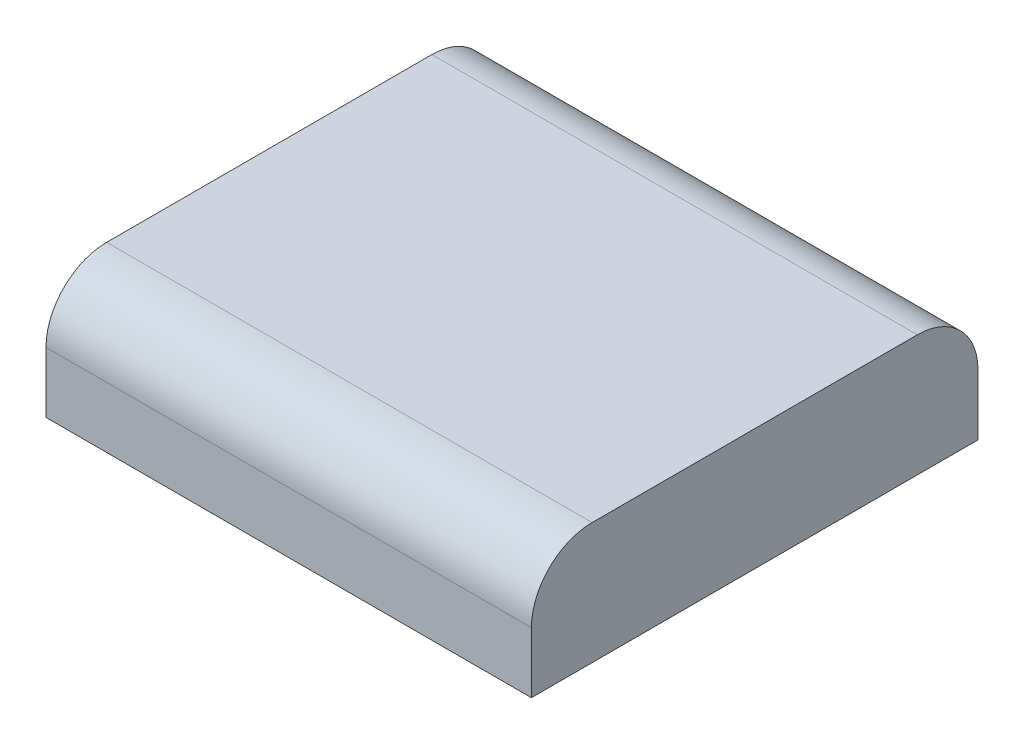
from build123d import *

# Parameters (mm, degrees)
SKETCH1_W           = 63.5
SKETCH1_H           = 58.42
BOSS_EXTRUDE1_DEPTH = 15.875
FILLET1_R           = 7.9375


with BuildPart() as part:
    # Sketch1 → Boss-Extrude1 (new body)
    with BuildSketch(Plane(origin=(0, 0, 0), x_dir=(1, 0, 0), z_dir=(0, 1, 0))):
        Rectangle(SKETCH1_W, SKETCH1_H)
    extrude(amount=BOSS_EXTRUDE1_DEPTH)

    # Fillet1
    fillet1_edges = [part.edges().sort_by_distance(p)[0] for p in [
        (0, 15.875, 29.21),
        (0, 15.875, -29.21),
    ]]
    fillet(fillet1_edges, radius=FILLET1_R)


solid = part.part
